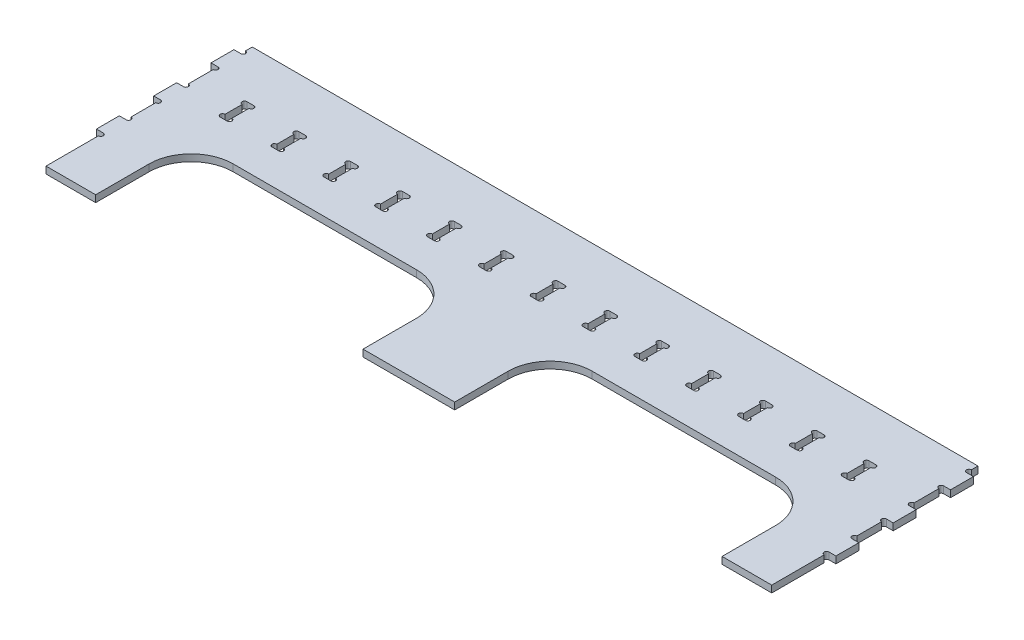
from build123d import *

# Parameters (mm, degrees)
BOSS_EXTRUDE1_DEPTH = 18
SKETCH1_3_W         = 18
SKETCH1_3_H         = 60
BOSS_EXTRUDE2_DEPTH = 18


with BuildPart() as part:
    # Sketch1 → Boss-Extrude1 (new body)
    with BuildSketch(Plane(origin=(0, 0, 0), x_dir=(1, 0, 0), z_dir=(0, 1, 0))):
        with BuildLine():
            Line((0, 540), (0, 522.7))
            ThreePointArc((0, 522.7), (6.35, 516.35), (0, 510))
            Line((0, 510), (0, 450))
            ThreePointArc((0, 450), (6.35, 443.65), (0, 437.3))
            Line((0, 437.3), (0, 372.7))
            ThreePointArc((0, 372.7), (6.35, 366.35), (0, 360))
            Line((0, 360), (0, 300))
            ThreePointArc((0, 300), (6.35, 293.65), (0, 287.3))
            Line((0, 287.3), (0, 222.7))
            ThreePointArc((0, 222.7), (6.35, 216.35), (0, 210))
            Line((0, 210), (0, 150))
            ThreePointArc((0, 150), (6.35, 143.65), (0, 137.3))
            Line((0, 137.3), (0, 0))
            Line((0, 0), (130, 0))
            Line((130, 0), (130, 140))
            ThreePointArc((130, 140), (162.218254069, 217.781745931), (240, 250))
            Line((240, 250), (720, 250))
            ThreePointArc((720, 250), (797.781745931, 217.781745931), (830, 140))
            Line((830, 140), (830, 0))
            Line((830, 0), (1070, 0))
            Line((1070, 0), (1070, 140))
            ThreePointArc((1070, 140), (1102.218254069, 217.781745931), (1180, 250))
            Line((1180, 250), (1660, 250))
            ThreePointArc((1660, 250), (1737.781745931, 217.781745931), (1770, 140))
            Line((1770, 140), (1770, 0))
            Line((1770, 0), (1900, 0))
            Line((1900, 0), (1900, 137.3))
            ThreePointArc((1900, 137.3), (1893.65, 143.65), (1900, 150))
            Line((1900, 150), (1918, 150))
            Line((1918, 150), (1918, 210))
            Line((1918, 210), (1900, 210))
            ThreePointArc((1900, 210), (1893.65, 216.35), (1900, 222.7))
            Line((1900, 222.7), (1900, 287.3))
            ThreePointArc((1900, 287.3), (1893.65, 293.65), (1900, 300))
            Line((1900, 300), (1918, 300))
            Line((1918, 300), (1918, 360))
            Line((1918, 360), (1900, 360))
            ThreePointArc((1900, 360), (1893.65, 366.35), (1900, 372.7))
            Line((1900, 372.7), (1900, 437.3))
            ThreePointArc((1900, 437.3), (1893.65, 443.65), (1900, 450))
            Line((1900, 450), (1918, 450))
            Line((1918, 450), (1918, 510))
            Line((1918, 510), (1900, 510))
            ThreePointArc((1900, 510), (1893.65, 516.35), (1900, 522.7))
            Line((1900, 522.7), (1900, 540))
            Line((1900, 540), (0, 540))
        make_face()
        with BuildLine():
            ThreePointArc((134.878049989, 351.824242509), (141.228049989, 345.474242509), (134.878049989, 339.124242509))
            Line((134.878049989, 339.124242509), (116.878049989, 339.124242509))
            ThreePointArc((116.878049989, 339.124242509), (110.528049989, 345.474242509), (116.878049989, 351.824242509))
            Line((116.878049989, 351.824242509), (116.878049989, 396.424242509))
            ThreePointArc((116.878049989, 396.424242509), (110.528049989, 402.774242509), (116.878049989, 409.124242509))
            Line((116.878049989, 409.124242509), (134.878049989, 409.124242509))
            ThreePointArc((134.878049989, 409.124242509), (141.228049989, 402.774242509), (134.878049989, 396.424242509))
            Line((134.878049989, 396.424242509), (134.878049989, 351.824242509))
        make_face(mode=Mode.SUBTRACT)
        with BuildLine():
            Line((270.588049989, 396.424242509), (270.588049989, 351.824242509))
            ThreePointArc((270.588049989, 351.824242509), (276.938049989, 345.474242509), (270.588049989, 339.124242509))
            Line((270.588049989, 339.124242509), (252.588049989, 339.124242509))
            ThreePointArc((252.588049989, 339.124242509), (246.238049989, 345.474242509), (252.588049989, 351.824242509))
            Line((252.588049989, 351.824242509), (252.588049989, 396.424242509))
            ThreePointArc((252.588049989, 396.424242509), (246.238049989, 402.774242509), (252.588049989, 409.124242509))
            Line((252.588049989, 409.124242509), (270.588049989, 409.124242509))
            ThreePointArc((270.588049989, 409.124242509), (276.938049989, 402.774242509), (270.588049989, 396.424242509))
        make_face(mode=Mode.SUBTRACT)
        with BuildLine():
            Line((406.298049989, 396.424242509), (406.298049989, 351.824242509))
            ThreePointArc((406.298049989, 351.824242509), (412.648049989, 345.474242509), (406.298049989, 339.124242509))
            Line((406.298049989, 339.124242509), (388.298049989, 339.124242509))
            ThreePointArc((388.298049989, 339.124242509), (381.948049989, 345.474242509), (388.298049989, 351.824242509))
            Line((388.298049989, 351.824242509), (388.298049989, 396.424242509))
            ThreePointArc((388.298049989, 396.424242509), (381.948049989, 402.774242509), (388.298049989, 409.124242509))
            Line((388.298049989, 409.124242509), (406.298049989, 409.124242509))
            ThreePointArc((406.298049989, 409.124242509), (412.648049989, 402.774242509), (406.298049989, 396.424242509))
        make_face(mode=Mode.SUBTRACT)
        with BuildLine():
            Line((542.008049989, 396.424242509), (542.008049989, 351.824242509))
            ThreePointArc((542.008049989, 351.824242509), (548.358049989, 345.474242509), (542.008049989, 339.124242509))
            Line((542.008049989, 339.124242509), (524.008049989, 339.124242509))
            ThreePointArc((524.008049989, 339.124242509), (517.658049989, 345.474242509), (524.008049989, 351.824242509))
            Line((524.008049989, 351.824242509), (524.008049989, 396.424242509))
            ThreePointArc((524.008049989, 396.424242509), (517.658049989, 402.774242509), (524.008049989, 409.124242509))
            Line((524.008049989, 409.124242509), (542.008049989, 409.124242509))
            ThreePointArc((542.008049989, 409.124242509), (548.358049989, 402.774242509), (542.008049989, 396.424242509))
        make_face(mode=Mode.SUBTRACT)
        with BuildLine():
            Line((677.718049989, 396.424242509), (677.718049989, 351.824242509))
            ThreePointArc((677.718049989, 351.824242509), (684.068049989, 345.474242509), (677.718049989, 339.124242509))
            Line((677.718049989, 339.124242509), (659.718049989, 339.124242509))
            ThreePointArc((659.718049989, 339.124242509), (653.368049989, 345.474242509), (659.718049989, 351.824242509))
            Line((659.718049989, 351.824242509), (659.718049989, 396.424242509))
            ThreePointArc((659.718049989, 396.424242509), (653.368049989, 402.774242509), (659.718049989, 409.124242509))
            Line((659.718049989, 409.124242509), (677.718049989, 409.124242509))
            ThreePointArc((677.718049989, 409.124242509), (684.068049989, 402.774242509), (677.718049989, 396.424242509))
        make_face(mode=Mode.SUBTRACT)
        with BuildLine():
            Line((813.428049989, 396.424242509), (813.428049989, 351.824242509))
            ThreePointArc((813.428049989, 351.824242509), (819.778049989, 345.474242509), (813.428049989, 339.124242509))
            Line((813.428049989, 339.124242509), (795.428049989, 339.124242509))
            ThreePointArc((795.428049989, 339.124242509), (789.078049989, 345.474242509), (795.428049989, 351.824242509))
            Line((795.428049989, 351.824242509), (795.428049989, 396.424242509))
            ThreePointArc((795.428049989, 396.424242509), (789.078049989, 402.774242509), (795.428049989, 409.124242509))
            Line((795.428049989, 409.124242509), (813.428049989, 409.124242509))
            ThreePointArc((813.428049989, 409.124242509), (819.778049989, 402.774242509), (813.428049989, 396.424242509))
        make_face(mode=Mode.SUBTRACT)
        with BuildLine():
            Line((949.138049989, 396.424242509), (949.138049989, 351.824242509))
            ThreePointArc((949.138049989, 351.824242509), (955.488049989, 345.474242509), (949.138049989, 339.124242509))
            Line((949.138049989, 339.124242509), (931.138049989, 339.124242509))
            ThreePointArc((931.138049989, 339.124242509), (924.788049989, 345.474242509), (931.138049989, 351.824242509))
            Line((931.138049989, 351.824242509), (931.138049989, 396.424242509))
            ThreePointArc((931.138049989, 396.424242509), (924.788049989, 402.774242509), (931.138049989, 409.124242509))
            Line((931.138049989, 409.124242509), (949.138049989, 409.124242509))
            ThreePointArc((949.138049989, 409.124242509), (955.488049989, 402.774242509), (949.138049989, 396.424242509))
        make_face(mode=Mode.SUBTRACT)
        with BuildLine():
            Line((1084.848049989, 396.424242509), (1084.848049989, 351.824242509))
            ThreePointArc((1084.848049989, 351.824242509), (1091.198049989, 345.474242509), (1084.848049989, 339.124242509))
            Line((1084.848049989, 339.124242509), (1066.848049989, 339.124242509))
            ThreePointArc((1066.848049989, 339.124242509), (1060.498049989, 345.474242509), (1066.848049989, 351.824242509))
            Line((1066.848049989, 351.824242509), (1066.848049989, 396.424242509))
            ThreePointArc((1066.848049989, 396.424242509), (1060.498049989, 402.774242509), (1066.848049989, 409.124242509))
            Line((1066.848049989, 409.124242509), (1084.848049989, 409.124242509))
            ThreePointArc((1084.848049989, 409.124242509), (1091.198049989, 402.774242509), (1084.848049989, 396.424242509))
        make_face(mode=Mode.SUBTRACT)
        with BuildLine():
            Line((1220.558049989, 396.424242509), (1220.558049989, 351.824242509))
            ThreePointArc((1220.558049989, 351.824242509), (1226.908049989, 345.474242509), (1220.558049989, 339.124242509))
            Line((1220.558049989, 339.124242509), (1202.558049989, 339.124242509))
            ThreePointArc((1202.558049989, 339.124242509), (1196.208049989, 345.474242509), (1202.558049989, 351.824242509))
            Line((1202.558049989, 351.824242509), (1202.558049989, 396.424242509))
            ThreePointArc((1202.558049989, 396.424242509), (1196.208049989, 402.774242509), (1202.558049989, 409.124242509))
            Line((1202.558049989, 409.124242509), (1220.558049989, 409.124242509))
            ThreePointArc((1220.558049989, 409.124242509), (1226.908049989, 402.774242509), (1220.558049989, 396.424242509))
        make_face(mode=Mode.SUBTRACT)
        with BuildLine():
            Line((1356.268049989, 396.424242509), (1356.268049989, 351.824242509))
            ThreePointArc((1356.268049989, 351.824242509), (1362.618049989, 345.474242509), (1356.268049989, 339.124242509))
            Line((1356.268049989, 339.124242509), (1338.268049989, 339.124242509))
            ThreePointArc((1338.268049989, 339.124242509), (1331.918049989, 345.474242509), (1338.268049989, 351.824242509))
            Line((1338.268049989, 351.824242509), (1338.268049989, 396.424242509))
            ThreePointArc((1338.268049989, 396.424242509), (1331.918049989, 402.774242509), (1338.268049989, 409.124242509))
            Line((1338.268049989, 409.124242509), (1356.268049989, 409.124242509))
            ThreePointArc((1356.268049989, 409.124242509), (1362.618049989, 402.774242509), (1356.268049989, 396.424242509))
        make_face(mode=Mode.SUBTRACT)
        with BuildLine():
            Line((1491.978049989, 396.424242509), (1491.978049989, 351.824242509))
            ThreePointArc((1491.978049989, 351.824242509), (1498.328049989, 345.474242509), (1491.978049989, 339.124242509))
            Line((1491.978049989, 339.124242509), (1473.978049989, 339.124242509))
            ThreePointArc((1473.978049989, 339.124242509), (1467.628049989, 345.474242509), (1473.978049989, 351.824242509))
            Line((1473.978049989, 351.824242509), (1473.978049989, 396.424242509))
            ThreePointArc((1473.978049989, 396.424242509), (1467.628049989, 402.774242509), (1473.978049989, 409.124242509))
            Line((1473.978049989, 409.124242509), (1491.978049989, 409.124242509))
            ThreePointArc((1491.978049989, 409.124242509), (1498.328049989, 402.774242509), (1491.978049989, 396.424242509))
        make_face(mode=Mode.SUBTRACT)
        with BuildLine():
            Line((1627.688049989, 396.424242509), (1627.688049989, 351.824242509))
            ThreePointArc((1627.688049989, 351.824242509), (1634.038049989, 345.474242509), (1627.688049989, 339.124242509))
            Line((1627.688049989, 339.124242509), (1609.688049989, 339.124242509))
            ThreePointArc((1609.688049989, 339.124242509), (1603.338049989, 345.474242509), (1609.688049989, 351.824242509))
            Line((1609.688049989, 351.824242509), (1609.688049989, 396.424242509))
            ThreePointArc((1609.688049989, 396.424242509), (1603.338049989, 402.774242509), (1609.688049989, 409.124242509))
            Line((1609.688049989, 409.124242509), (1627.688049989, 409.124242509))
            ThreePointArc((1627.688049989, 409.124242509), (1634.038049989, 402.774242509), (1627.688049989, 396.424242509))
        make_face(mode=Mode.SUBTRACT)
        with BuildLine():
            Line((1763.398049989, 396.424242509), (1763.398049989, 351.824242509))
            ThreePointArc((1763.398049989, 351.824242509), (1769.748049989, 345.474242509), (1763.398049989, 339.124242509))
            Line((1763.398049989, 339.124242509), (1745.398049989, 339.124242509))
            ThreePointArc((1745.398049989, 339.124242509), (1739.048049989, 345.474242509), (1745.398049989, 351.824242509))
            Line((1745.398049989, 351.824242509), (1745.398049989, 396.424242509))
            ThreePointArc((1745.398049989, 396.424242509), (1739.048049989, 402.774242509), (1745.398049989, 409.124242509))
            Line((1745.398049989, 409.124242509), (1763.398049989, 409.124242509))
            ThreePointArc((1763.398049989, 409.124242509), (1769.748049989, 402.774242509), (1763.398049989, 396.424242509))
        make_face(mode=Mode.SUBTRACT)
    extrude(amount=BOSS_EXTRUDE1_DEPTH)

    # Sketch1_3 → Boss-Extrude2 (add)
    with BuildSketch(Plane(origin=(0, 0, 0), x_dir=(1, 0, 0), z_dir=(0, 1, 0))):
        with Locations((-9, 480)):
            Rectangle(SKETCH1_3_W, SKETCH1_3_H)
        with Locations((-9, 330)):
            Rectangle(SKETCH1_3_W, SKETCH1_3_H)
        with Locations((-9, 180)):
            Rectangle(SKETCH1_3_W, SKETCH1_3_H)
    extrude(amount=BOSS_EXTRUDE2_DEPTH)


solid = part.part
